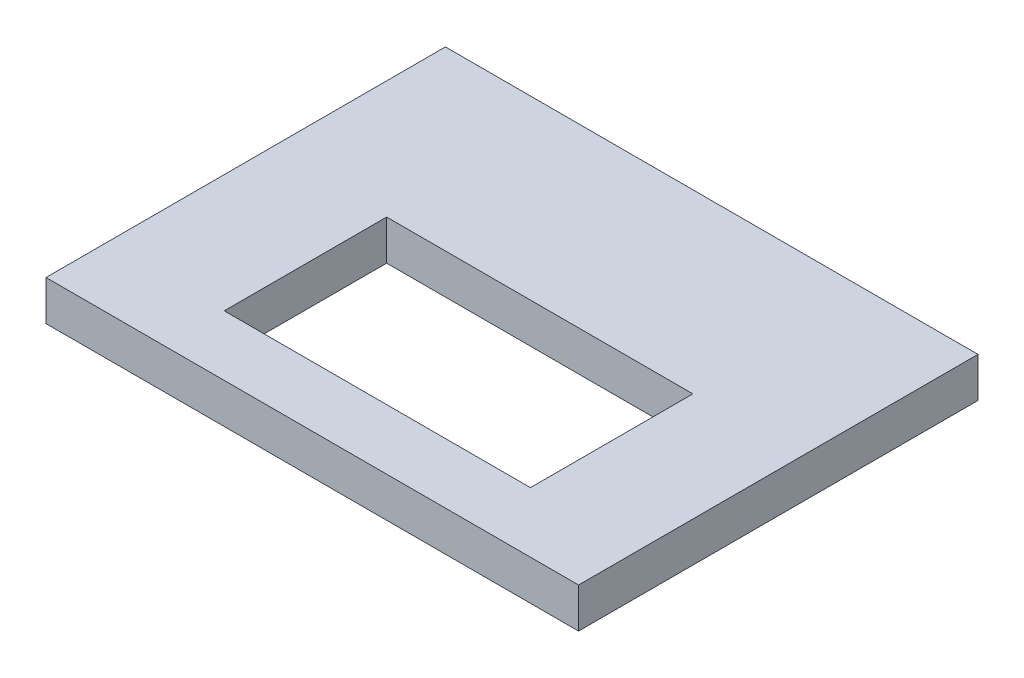
from build123d import *

# Parameters (mm, degrees)
SKETCH1_W           = 40
SKETCH1_H           = 30
SKETCH1_W_2         = 23
SKETCH1_H_2         = 12.2
BOSS_EXTRUDE1_DEPTH = 3


with BuildPart() as part:
    # Sketch1 → Boss-Extrude1 (new body)
    with BuildSketch(Plane(origin=(0, 0, 0), x_dir=(1, 0, 0), z_dir=(0, 1, 0))):
        with Locations((-35.875765281, -0.631601363)):
            Rectangle(SKETCH1_W, SKETCH1_H)
        with Locations((-35.515035206, -5.006788759)):
            Rectangle(SKETCH1_W_2, SKETCH1_H_2, mode=Mode.SUBTRACT)
    extrude(amount=BOSS_EXTRUDE1_DEPTH)


solid = part.part
